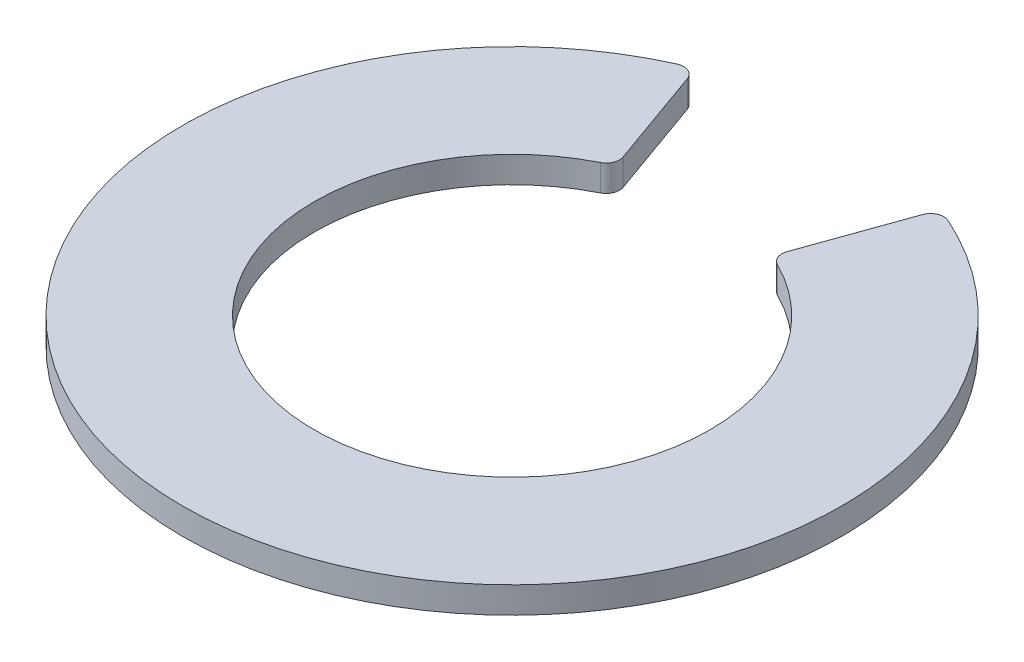
from build123d import *

# Parameters (mm, degrees)
BOSS_EXTRUDE1_DEPTH = 0.2


with BuildPart() as part:
    # Sketch4 → Boss-Extrude1 (new body)
    with BuildSketch(Plane(origin=(0, 0, 0), x_dir=(1, 0, 0), z_dir=(0, 1, 0))):
        with BuildLine():
            Line((-0.892301784, 2.221506026), (-0.62203599, 1.464364274))
            ThreePointArc((-0.62203599, 1.464364274), (-0.623420326, 1.393476941), (-0.671452287, 1.341324653))
            ThreePointArc((-0.671452287, 1.341324653), (0, -1.5), (0.671452287, 1.341324653))
            ThreePointArc((0.671452287, 1.341324653), (0.623420326, 1.393476941), (0.62203599, 1.464364274))
            Line((0.62203599, 1.464364274), (0.892301784, 2.221506026))
            ThreePointArc((0.892301784, 2.221506026), (0.947339463, 2.279909219), (1.027584966, 2.279050052))
            ThreePointArc((1.027584966, 2.279050052), (0, -2.5), (-1.027584966, 2.279050052))
            ThreePointArc((-1.027584966, 2.279050052), (-0.947339463, 2.279909219), (-0.892301784, 2.221506026))
        make_face()
    extrude(amount=BOSS_EXTRUDE1_DEPTH)


solid = part.part
